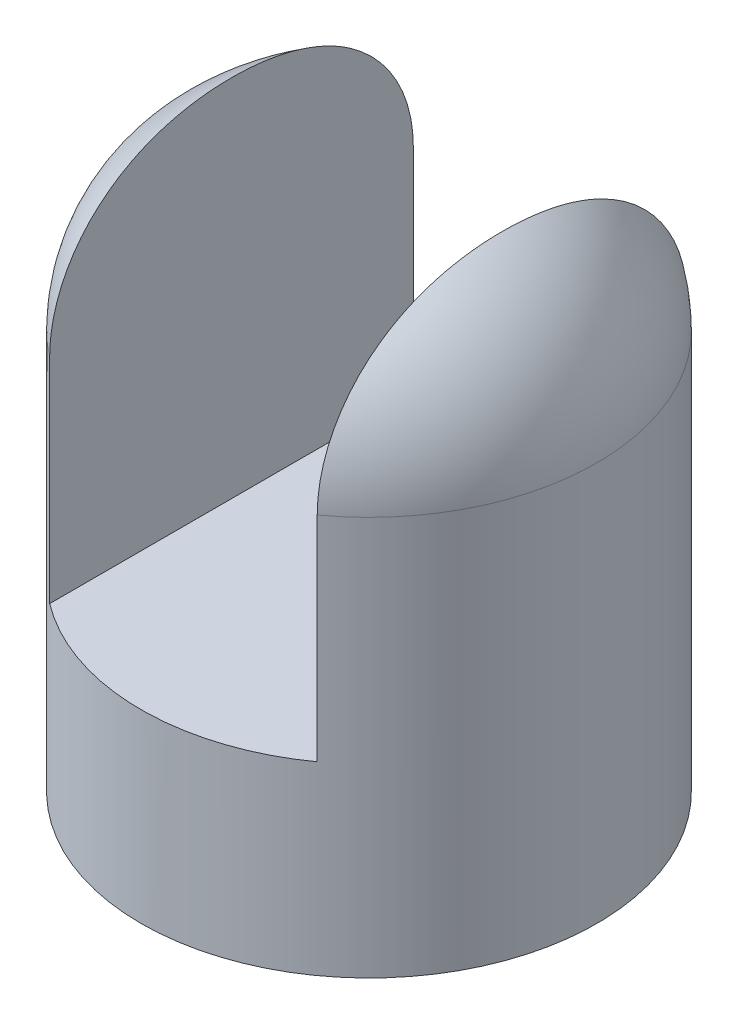
from build123d import *

# Parameters (mm, degrees)
SZKIC2_R                    = 80
DODANIE_WYCI_GNI_CIE2_DEPTH = 200
ZAOKR_GLENIE1_R             = 60
WYTNIJ_WYCI_GNI_CIE1_DEPTH  = 135


with BuildPart() as part:
    # Szkic2 → Dodanie-wyciągnięcie2 (new body)
    with BuildSketch(Plane(origin=(0, 0, 0), x_dir=(1, 0, 0), z_dir=(0, 1, 0))):
        Circle(SZKIC2_R)
    extrude(amount=DODANIE_WYCI_GNI_CIE2_DEPTH)

    # Zaokrąglenie1
    zaokr_glenie1_edges = [part.edges().sort_by_distance(p)[0] for p in [
        (-80, 200, 0),
    ]]
    fillet(zaokr_glenie1_edges, radius=ZAOKR_GLENIE1_R)

    # Szkic5 → Wytnij-wyciągnięcie1 (cut)
    with BuildSketch(Plane(origin=(0, 200, 0), x_dir=(1, 0, 0), z_dir=(0, 1, 0))):
        Polygon((46.75, 0), (46.75, 80.000117874), (-48.25, 80.000117874), (-48.25, 0), (-48.25, -80.000327), (46.75, -80.000327), align=None)
    extrude(amount=-WYTNIJ_WYCI_GNI_CIE1_DEPTH, mode=Mode.SUBTRACT)


solid = part.part
